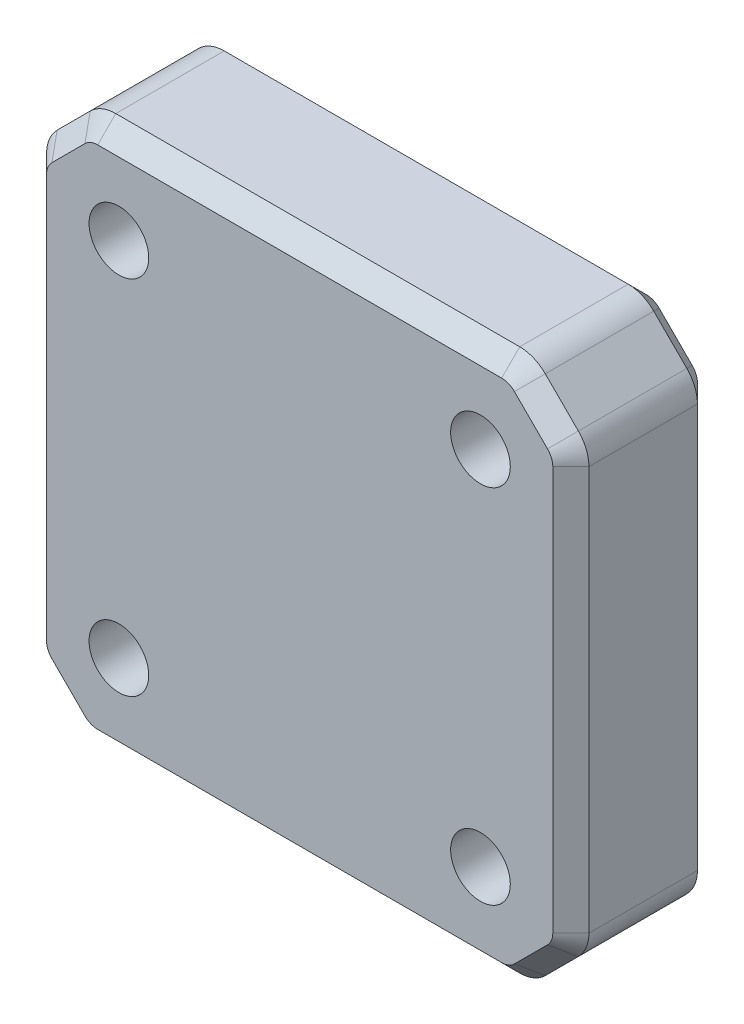
from build123d import *

# Parameters (mm, degrees)
SKETCH_1_W         = 30
SKETCH_1_H         = 30
EXTRUDE_1_DEPTH    = 8
HOLE_WIZARD_M4_1_D = 3.3
CHAMFER_1_SIZE     = 3
FILLET_1_R         = 2
CHAMFER_2_SIZE     = 1


with BuildPart() as part:
    # ｽｹｯﾁ1 → ﾎﾞｽ - 押し出し1 (new body)
    with BuildSketch(Plane.XY):
        Rectangle(SKETCH_1_W, SKETCH_1_H)
    extrude(amount=EXTRUDE_1_DEPTH)

    # M4 すきま穴1 (through all)
    with Locations(Plane.XY.offset(8)):
        with Locations((-10, 10), (-10, -10), (10, -10), (10, 10)):
            Hole(HOLE_WIZARD_M4_1_D / 2)

    # 面取り1
    chamfer_1_edges = [part.edges().sort_by_distance(p)[0] for p in [
        (-15, 15, 4),
        (15, 15, 4),
        (15, -15, 4),
        (-15, -15, 4),
    ]]
    chamfer(chamfer_1_edges, length=CHAMFER_1_SIZE)

    # ﾌｨﾚｯﾄ1
    fillet_1_edges = [part.edges().sort_by_distance(p)[0] for p in [
        (-12, 15, 4),
        (12, 15, 4),
        (15, -12, 4),
        (15, 12, 4),
        (-15, -12, 4),
        (-15, 12, 4),
        (-12, -15, 4),
        (12, -15, 4),
    ]]
    fillet(fillet_1_edges, radius=FILLET_1_R)

    # 面取り2
    chamfer_2_edges = [part.edges().sort_by_distance(p)[0] for p in [
        (15, 0, 0),
        (15, 0, 8),
        (13.5, 13.5, 8),
        (0, 15, 8),
        (-13.5, 13.5, 8),
        (-15, 0, 8),
        (-13.5, -13.5, 8),
        (0, -15, 8),
        (13.5, -13.5, 8),
        (11.93693974, -14.847759065, 8),
        (14.847759065, -11.93693974, 8),
        (-11.93693974, -14.847759065, 8),
        (-14.847759065, -11.93693974, 8),
        (-14.847759065, 11.93693974, 8),
        (-11.93693974, 14.847759065, 8),
        (11.93693974, 14.847759065, 8),
        (14.847759065, 11.93693974, 8),
        (13.5, 13.5, 0),
        (0, 15, 0),
        (13.5, -13.5, 0),
        (0, -15, 0),
        (-13.5, -13.5, 0),
        (-15, 0, 0),
        (-13.5, 13.5, 0),
        (11.93693974, -14.847759065, 0),
        (14.847759065, -11.93693974, 0),
        (-11.93693974, -14.847759065, 0),
        (-14.847759065, -11.93693974, 0),
        (-14.847759065, 11.93693974, 0),
        (-11.93693974, 14.847759065, 0),
        (11.93693974, 14.847759065, 0),
        (14.847759065, 11.93693974, 0),
    ]]
    chamfer(chamfer_2_edges, length=CHAMFER_2_SIZE)


solid = part.part
